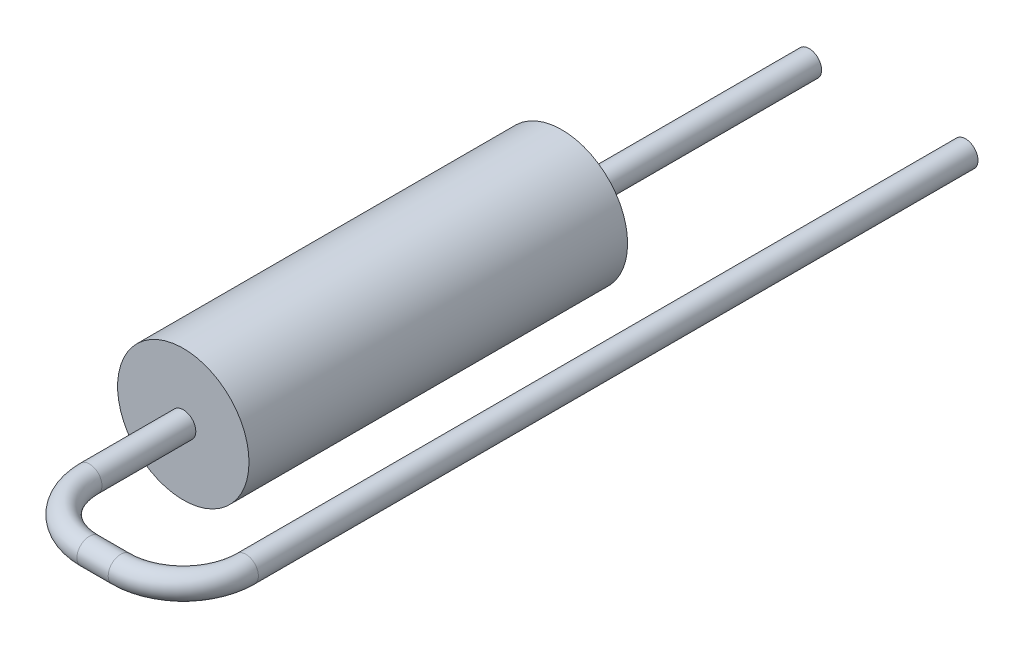
from build123d import *

# Parameters (mm, degrees)
SKETCH2_R           = 2.1
RESISTOR_BODY_DEPTH = 12.1
LEAD1_PROFILE_R     = 0.4
SKETCH6_R           = 0.4
LEAD2_DEPTH         = 7.9


with BuildPart() as part:
    # Sketch2 → Resistor Body (new body)
    with BuildSketch(Plane.XY):
        Circle(SKETCH2_R)
    extrude(amount=RESISTOR_BODY_DEPTH)

    # Lead1: sweep along a path in Lead1 Path
    with BuildLine(Plane(origin=(0, 0, 0), x_dir=(1, 0, 0), z_dir=(0, 1, 0))) as lead1_path:
        Line((0, -12.1), (0, -15.1))
        ThreePointArc((0, -15.1), (0.585786438, -16.514213562), (2, -17.1))
        Line((2, -17.1), (3, -17.1))
        ThreePointArc((3, -17.1), (4.414213562, -16.514213562), (5, -15.1))
        Line((5, -15.1), (5, 7.9))
    # Lead1 Profile → Lead1 (sweep)
    with BuildSketch(Plane(origin=(0, 0, 12.1), x_dir=(-1, 0, 0), z_dir=(0, 0, 1))):
        Circle(LEAD1_PROFILE_R)
    sweep(path=lead1_path.line)

    # Sketch6 → Lead2 (add)
    with BuildSketch(Plane(origin=(0, 0, 0), x_dir=(1, 0, 0), z_dir=(0, 0, -1))):
        Circle(SKETCH6_R)
    extrude(amount=LEAD2_DEPTH)


solid = part.part
